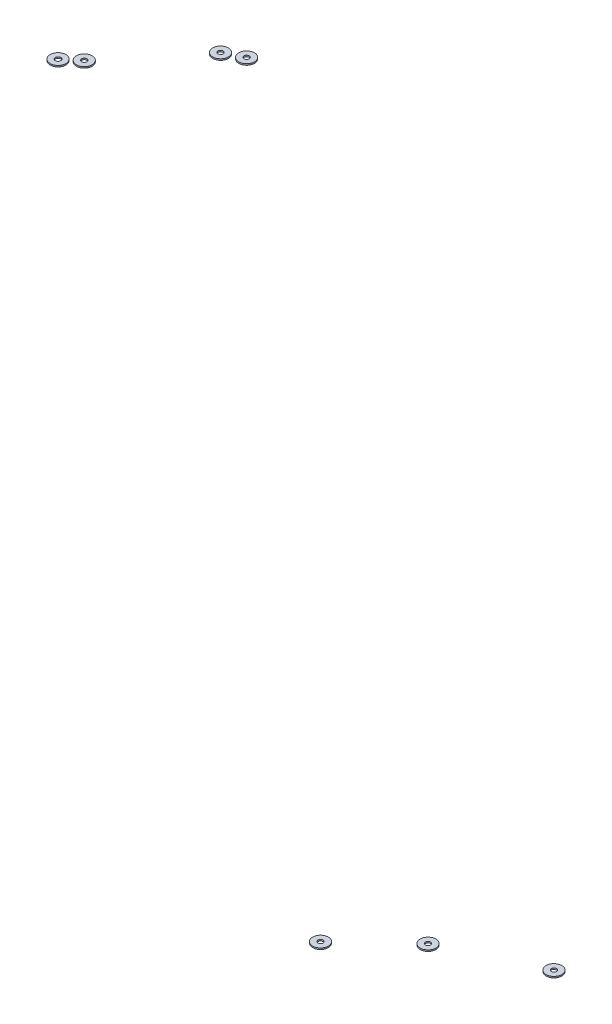
from build123d import *

# Parameters (mm, degrees)
SZKIC1_R                      = 4.5
SZKIC1_R_2                    = 1.5
DODANIE_WYCI_GNI_CIE1_DEPTH   = 0.8
DODANIE_WYCI_GNI_CIE1_2_DEPTH = 0.8
DODANIE_WYCI_GNI_CIE1_3_DEPTH = 0.8
SZKIC1_R_3                    = 1.605914525
DODANIE_WYCI_GNI_CIE1_4_DEPTH = 0.8
SZKIC2_R                      = 4.5
SZKIC2_R_2                    = 1.5
DODANIE_WYCI_GNI_CIE2_DEPTH   = 0.8
DODANIE_WYCI_GNI_CIE2_2_DEPTH = 0.8
DODANIE_WYCI_GNI_CIE2_3_DEPTH = 0.8


with BuildPart() as part:
    # Szkic1 → Dodanie-wyciągnięcie1 (new body)
    with BuildSketch(Plane(origin=(0, 705.3, 0), x_dir=(1, 0, 0), z_dir=(0, 1, 0))):
        with Locations((-421.090050281, -327.725114352)):
            Circle(SZKIC1_R)
        with Locations((-421.090050281, -327.725114352)):
            Circle(SZKIC1_R_2, mode=Mode.SUBTRACT)
    extrude(amount=DODANIE_WYCI_GNI_CIE1_DEPTH)


with BuildPart() as body_2:
    # Szkic1 → Dodanie-wyci_gni_cie1 2 (new body)
    with BuildSketch(Plane(origin=(0, 705.3, 0), x_dir=(1, 0, 0), z_dir=(0, 1, 0))):
        with Locations((-431.039698402, -332.774189517)):
            Circle(SZKIC1_R)
        with Locations((-431.039698402, -332.774189517)):
            Circle(SZKIC1_R_2, mode=Mode.SUBTRACT)
    extrude(amount=DODANIE_WYCI_GNI_CIE1_2_DEPTH)


with BuildPart() as body_3:
    # Szkic1 → Dodanie-wyci_gni_cie1 3 (new body)
    with BuildSketch(Plane(origin=(0, 705.3, 0), x_dir=(1, 0, 0), z_dir=(0, 1, 0))):
        with Locations((-466.308050674, -375.85941501)):
            Circle(SZKIC1_R)
        with Locations((-466.308050674, -375.85941501)):
            Circle(SZKIC1_R_2, mode=Mode.SUBTRACT)
    extrude(amount=DODANIE_WYCI_GNI_CIE1_3_DEPTH)


with BuildPart() as body_4:
    # Szkic1 → Dodanie-wyci_gni_cie1 4 (new body)
    with BuildSketch(Plane(origin=(0, 705.3, 0), x_dir=(1, 0, 0), z_dir=(0, 1, 0))):
        with Locations((-474.449169572, -382.793687092)):
            Circle(SZKIC1_R)
        with Locations((-474.449169572, -382.793687092)):
            Circle(SZKIC1_R_3, mode=Mode.SUBTRACT)
    extrude(amount=DODANIE_WYCI_GNI_CIE1_4_DEPTH)


with BuildPart() as body_5:
    # Szkic2 → Dodanie-wyciągnięcie2 (new body)
    with BuildSketch(Plane.XZ.offset(-294.7)):
        with Locations((-370.956911026, 335.367132453)):
            Circle(SZKIC2_R)
        with Locations((-370.956911026, 335.367132453)):
            Circle(SZKIC2_R_2, mode=Mode.SUBTRACT)
    extrude(amount=DODANIE_WYCI_GNI_CIE2_DEPTH)


with BuildPart() as body_6:
    # Szkic2 → Dodanie-wyci_gni_cie2 2 (new body)
    with BuildSketch(Plane.XZ.offset(-294.7)):
        with Locations((-339.082998521, 305.429754445)):
            Circle(SZKIC2_R)
        with Locations((-339.082998521, 305.429754445)):
            Circle(SZKIC2_R_2, mode=Mode.SUBTRACT)
    extrude(amount=DODANIE_WYCI_GNI_CIE2_2_DEPTH)


with BuildPart() as body_7:
    # Szkic2 → Dodanie-wyci_gni_cie2 3 (new body)
    with BuildSketch(Plane.XZ.offset(-294.7)):
        with Locations((-289.68705591, 282.424125213)):
            Circle(SZKIC2_R)
        with Locations((-289.68705591, 282.424125213)):
            Circle(SZKIC2_R_2, mode=Mode.SUBTRACT)
    extrude(amount=DODANIE_WYCI_GNI_CIE2_3_DEPTH)


solid = Compound([part.part, body_2.part, body_3.part, body_4.part, body_5.part, body_6.part, body_7.part])
